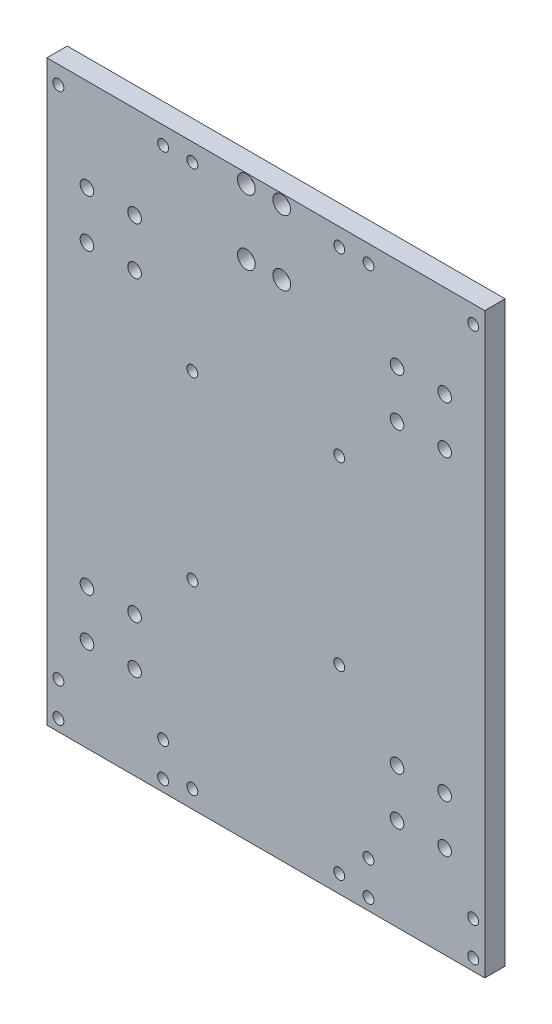
from build123d import *

# Parameters (mm, degrees)
SZKIC1_W                       = 322
SZKIC1_H                       = 425
DODANIE_WYCI_GNI_CIE1_DEPTH    = 15
SZKIC2_R                       = 3
WYTNIJ_WYCI_GNI_CIE1_DEPTH     = 15
SZKIC3_R                       = 5
WYTNIJ_WYCI_GNI_CIE2_DEPTH     = 7
SZYK_LINIOWY1_COUNT            = 2
SZYK_LINIOWY1_PITCH            = 35
SZYK_LINIOWY1_COUNT_DIR2       = 2
SZYK_LINIOWY1_PITCH_DIR2       = 35
SZYK_LINIOWY2_COUNT            = 2
SZYK_LINIOWY2_PITCH            = 228
SZYK_LINIOWY2_COUNT_DIR2       = 2
SZYK_LINIOWY2_PITCH_DIR2       = 254
SZYK_LINIOWY2_COPY_1_SKETCH_R  = 3
SZYK_LINIOWY2_COPY_1_DEPTH     = 15
SZYK_LINIOWY2_COPY_2_SKETCH_R  = 3
SZYK_LINIOWY2_COPY_2_DEPTH     = 15
SZYK_LINIOWY2_COPY_3_SKETCH_R  = 3
SZYK_LINIOWY2_COPY_3_DEPTH     = 15
SZYK_LINIOWY2_COPY_4_SKETCH_R  = 3
SZYK_LINIOWY2_COPY_4_DEPTH     = 15
SZYK_LINIOWY2_COPY_5_SKETCH_R  = 3
SZYK_LINIOWY2_COPY_5_DEPTH     = 15
SZYK_LINIOWY2_COPY_6_SKETCH_R  = 3
SZYK_LINIOWY2_COPY_6_DEPTH     = 15
SZYK_LINIOWY2_COPY_7_SKETCH_R  = 3
SZYK_LINIOWY2_COPY_7_DEPTH     = 15
SZYK_LINIOWY2_COPY_8_SKETCH_R  = 3
SZYK_LINIOWY2_COPY_8_DEPTH     = 15
SZYK_LINIOWY2_COPY_9_SKETCH_R  = 3
SZYK_LINIOWY2_COPY_9_DEPTH     = 15
SZYK_LINIOWY2_COPY_10_SKETCH_R = 5
SZYK_LINIOWY2_COPY_10_DEPTH    = 7
SZYK_LINIOWY2_COPY_11_SKETCH_R = 5
SZYK_LINIOWY2_COPY_11_DEPTH    = 7
SZYK_LINIOWY2_COPY_12_SKETCH_R = 5
SZYK_LINIOWY2_COPY_12_DEPTH    = 7
SZYK_LINIOWY2_COPY_13_SKETCH_R = 5
SZYK_LINIOWY2_COPY_13_DEPTH    = 7
SZYK_LINIOWY2_COPY_14_SKETCH_R = 5
SZYK_LINIOWY2_COPY_14_DEPTH    = 7
SZYK_LINIOWY2_COPY_15_SKETCH_R = 5
SZYK_LINIOWY2_COPY_15_DEPTH    = 7
SZYK_LINIOWY2_COPY_16_SKETCH_R = 5
SZYK_LINIOWY2_COPY_16_DEPTH    = 7
SZYK_LINIOWY2_COPY_17_SKETCH_R = 5
SZYK_LINIOWY2_COPY_17_DEPTH    = 7
SZYK_LINIOWY2_COPY_18_SKETCH_R = 5
SZYK_LINIOWY2_COPY_18_DEPTH    = 7
SZKIC6_R                       = 4
WYTNIJ_WYCI_GNI_CIE3_DEPTH     = 20
SZKIC7_R                       = 4
WYTNIJ_WYCI_GNI_CIE4_DEPTH     = 20
SZKIC10_R                      = 4
WYTNIJ_WYCI_GNI_CIE5_DEPTH     = 21
SZKIC11_R                      = 4
WYTNIJ_WYCI_GNI_CIE6_DEPTH     = 21
SZKIC12_R                      = 3.999999999
WYTNIJ_WYCI_GNI_CIE7_DEPTH     = 15
SZKIC13_R                      = 6.499999999
WYTNIJ_WYCI_GNI_CIE8_DEPTH     = 9
SZKIC14_R                      = 4
WYTNIJ_WYCI_GNI_CIE9_DEPTH     = 15
SZYK_LINIOWY3_COUNT            = 4
SZYK_LINIOWY3_PITCH            = 133


with BuildPart() as part:
    # Szkic1 → Dodanie-wyciągnięcie1 (new body)
    with BuildSketch(Plane.XY):
        Rectangle(SZKIC1_W, SZKIC1_H)
    extrude(amount=DODANIE_WYCI_GNI_CIE1_DEPTH)

    # Szkic2 → Wytnij-wyciągnięcie1 (cut)
    with BuildSketch(Plane.XY.offset(15)):
        with Locations((-131.5, 144.5)):
            Circle(SZKIC2_R)
    wytnij_wyci_gni_cie1 = extrude(amount=-WYTNIJ_WYCI_GNI_CIE1_DEPTH, mode=Mode.SUBTRACT)

    # Szkic3 → Wytnij-wyciągnięcie2 (cut)
    with BuildSketch(Plane.XY.offset(15)):
        with Locations((-131.5, 144.5)):
            Circle(SZKIC3_R)
    wytnij_wyci_gni_cie2 = extrude(amount=-WYTNIJ_WYCI_GNI_CIE2_DEPTH, mode=Mode.SUBTRACT)

    # Szyk liniowy1: Wytnij-wyciągnięcie1, Wytnij-wyci_gni_cie2 2 × 2
    with Locations(*[(i * SZYK_LINIOWY1_PITCH, -j * SZYK_LINIOWY1_PITCH_DIR2, 0) for i in range(SZYK_LINIOWY1_COUNT) for j in range(SZYK_LINIOWY1_COUNT_DIR2) if (i, j) != (0, 0)]):
        add(wytnij_wyci_gni_cie1, mode=Mode.SUBTRACT)
        add(wytnij_wyci_gni_cie2, mode=Mode.SUBTRACT)

    # Szyk liniowy2: Wytnij-wyciągnięcie1, Wytnij-wyci_gni_cie2 2 × 2
    with Locations(*[(i * SZYK_LINIOWY2_PITCH, -j * SZYK_LINIOWY2_PITCH_DIR2, 0) for i in range(SZYK_LINIOWY2_COUNT) for j in range(SZYK_LINIOWY2_COUNT_DIR2) if (i, j) != (0, 0)]):
        add(wytnij_wyci_gni_cie1, mode=Mode.SUBTRACT)
        add(wytnij_wyci_gni_cie2, mode=Mode.SUBTRACT)

    # Szyk liniowy2 copy 1 sketch → Szyk liniowy2 copy 1 (cut)
    with BuildSketch(Plane(origin=(0, -289, 15), x_dir=(1, 0, 0), z_dir=(0, 0, 1))):
        with Locations((-131.5, 144.5)):
            Circle(SZYK_LINIOWY2_COPY_1_SKETCH_R)
    extrude(amount=-SZYK_LINIOWY2_COPY_1_DEPTH, mode=Mode.SUBTRACT)

    # Szyk liniowy2 copy 2 sketch → Szyk liniowy2 copy 2 (cut)
    with BuildSketch(Plane(origin=(228, -35, 15), x_dir=(1, 0, 0), z_dir=(0, 0, 1))):
        with Locations((-131.5, 144.5)):
            Circle(SZYK_LINIOWY2_COPY_2_SKETCH_R)
    extrude(amount=-SZYK_LINIOWY2_COPY_2_DEPTH, mode=Mode.SUBTRACT)

    # Szyk liniowy2 copy 3 sketch → Szyk liniowy2 copy 3 (cut)
    with BuildSketch(Plane(origin=(228, -289, 15), x_dir=(1, 0, 0), z_dir=(0, 0, 1))):
        with Locations((-131.5, 144.5)):
            Circle(SZYK_LINIOWY2_COPY_3_SKETCH_R)
    extrude(amount=-SZYK_LINIOWY2_COPY_3_DEPTH, mode=Mode.SUBTRACT)

    # Szyk liniowy2 copy 4 sketch → Szyk liniowy2 copy 4 (cut)
    with BuildSketch(Plane(origin=(35, -254, 15), x_dir=(1, 0, 0), z_dir=(0, 0, 1))):
        with Locations((-131.5, 144.5)):
            Circle(SZYK_LINIOWY2_COPY_4_SKETCH_R)
    extrude(amount=-SZYK_LINIOWY2_COPY_4_DEPTH, mode=Mode.SUBTRACT)

    # Szyk liniowy2 copy 5 sketch → Szyk liniowy2 copy 5 (cut)
    with BuildSketch(Plane(origin=(263, 0, 15), x_dir=(1, 0, 0), z_dir=(0, 0, 1))):
        with Locations((-131.5, 144.5)):
            Circle(SZYK_LINIOWY2_COPY_5_SKETCH_R)
    extrude(amount=-SZYK_LINIOWY2_COPY_5_DEPTH, mode=Mode.SUBTRACT)

    # Szyk liniowy2 copy 6 sketch → Szyk liniowy2 copy 6 (cut)
    with BuildSketch(Plane(origin=(263, -254, 15), x_dir=(1, 0, 0), z_dir=(0, 0, 1))):
        with Locations((-131.5, 144.5)):
            Circle(SZYK_LINIOWY2_COPY_6_SKETCH_R)
    extrude(amount=-SZYK_LINIOWY2_COPY_6_DEPTH, mode=Mode.SUBTRACT)

    # Szyk liniowy2 copy 7 sketch → Szyk liniowy2 copy 7 (cut)
    with BuildSketch(Plane(origin=(35, -289, 15), x_dir=(1, 0, 0), z_dir=(0, 0, 1))):
        with Locations((-131.5, 144.5)):
            Circle(SZYK_LINIOWY2_COPY_7_SKETCH_R)
    extrude(amount=-SZYK_LINIOWY2_COPY_7_DEPTH, mode=Mode.SUBTRACT)

    # Szyk liniowy2 copy 8 sketch → Szyk liniowy2 copy 8 (cut)
    with BuildSketch(Plane(origin=(263, -35, 15), x_dir=(1, 0, 0), z_dir=(0, 0, 1))):
        with Locations((-131.5, 144.5)):
            Circle(SZYK_LINIOWY2_COPY_8_SKETCH_R)
    extrude(amount=-SZYK_LINIOWY2_COPY_8_DEPTH, mode=Mode.SUBTRACT)

    # Szyk liniowy2 copy 9 sketch → Szyk liniowy2 copy 9 (cut)
    with BuildSketch(Plane(origin=(263, -289, 15), x_dir=(1, 0, 0), z_dir=(0, 0, 1))):
        with Locations((-131.5, 144.5)):
            Circle(SZYK_LINIOWY2_COPY_9_SKETCH_R)
    extrude(amount=-SZYK_LINIOWY2_COPY_9_DEPTH, mode=Mode.SUBTRACT)

    # Szyk liniowy2 copy 10 sketch → Szyk liniowy2 copy 10 (cut)
    with BuildSketch(Plane(origin=(0, -289, 15), x_dir=(1, 0, 0), z_dir=(0, 0, 1))):
        with Locations((-131.5, 144.5)):
            Circle(SZYK_LINIOWY2_COPY_10_SKETCH_R)
    extrude(amount=-SZYK_LINIOWY2_COPY_10_DEPTH, mode=Mode.SUBTRACT)

    # Szyk liniowy2 copy 11 sketch → Szyk liniowy2 copy 11 (cut)
    with BuildSketch(Plane(origin=(228, -35, 15), x_dir=(1, 0, 0), z_dir=(0, 0, 1))):
        with Locations((-131.5, 144.5)):
            Circle(SZYK_LINIOWY2_COPY_11_SKETCH_R)
    extrude(amount=-SZYK_LINIOWY2_COPY_11_DEPTH, mode=Mode.SUBTRACT)

    # Szyk liniowy2 copy 12 sketch → Szyk liniowy2 copy 12 (cut)
    with BuildSketch(Plane(origin=(228, -289, 15), x_dir=(1, 0, 0), z_dir=(0, 0, 1))):
        with Locations((-131.5, 144.5)):
            Circle(SZYK_LINIOWY2_COPY_12_SKETCH_R)
    extrude(amount=-SZYK_LINIOWY2_COPY_12_DEPTH, mode=Mode.SUBTRACT)

    # Szyk liniowy2 copy 13 sketch → Szyk liniowy2 copy 13 (cut)
    with BuildSketch(Plane(origin=(35, -254, 15), x_dir=(1, 0, 0), z_dir=(0, 0, 1))):
        with Locations((-131.5, 144.5)):
            Circle(SZYK_LINIOWY2_COPY_13_SKETCH_R)
    extrude(amount=-SZYK_LINIOWY2_COPY_13_DEPTH, mode=Mode.SUBTRACT)

    # Szyk liniowy2 copy 14 sketch → Szyk liniowy2 copy 14 (cut)
    with BuildSketch(Plane(origin=(263, 0, 15), x_dir=(1, 0, 0), z_dir=(0, 0, 1))):
        with Locations((-131.5, 144.5)):
            Circle(SZYK_LINIOWY2_COPY_14_SKETCH_R)
    extrude(amount=-SZYK_LINIOWY2_COPY_14_DEPTH, mode=Mode.SUBTRACT)

    # Szyk liniowy2 copy 15 sketch → Szyk liniowy2 copy 15 (cut)
    with BuildSketch(Plane(origin=(263, -254, 15), x_dir=(1, 0, 0), z_dir=(0, 0, 1))):
        with Locations((-131.5, 144.5)):
            Circle(SZYK_LINIOWY2_COPY_15_SKETCH_R)
    extrude(amount=-SZYK_LINIOWY2_COPY_15_DEPTH, mode=Mode.SUBTRACT)

    # Szyk liniowy2 copy 16 sketch → Szyk liniowy2 copy 16 (cut)
    with BuildSketch(Plane(origin=(35, -289, 15), x_dir=(1, 0, 0), z_dir=(0, 0, 1))):
        with Locations((-131.5, 144.5)):
            Circle(SZYK_LINIOWY2_COPY_16_SKETCH_R)
    extrude(amount=-SZYK_LINIOWY2_COPY_16_DEPTH, mode=Mode.SUBTRACT)

    # Szyk liniowy2 copy 17 sketch → Szyk liniowy2 copy 17 (cut)
    with BuildSketch(Plane(origin=(263, -35, 15), x_dir=(1, 0, 0), z_dir=(0, 0, 1))):
        with Locations((-131.5, 144.5)):
            Circle(SZYK_LINIOWY2_COPY_17_SKETCH_R)
    extrude(amount=-SZYK_LINIOWY2_COPY_17_DEPTH, mode=Mode.SUBTRACT)

    # Szyk liniowy2 copy 18 sketch → Szyk liniowy2 copy 18 (cut)
    with BuildSketch(Plane(origin=(263, -289, 15), x_dir=(1, 0, 0), z_dir=(0, 0, 1))):
        with Locations((-131.5, 144.5)):
            Circle(SZYK_LINIOWY2_COPY_18_SKETCH_R)
    extrude(amount=-SZYK_LINIOWY2_COPY_18_DEPTH, mode=Mode.SUBTRACT)

    # Szkic6 → Wytnij-wyciągnięcie3 (cut)
    with BuildSketch(Plane.XY.offset(15)):
        with Locations((-152.5, 199.5)):
            Circle(SZKIC6_R)
        with Locations((-75.5, 199.5)):
            Circle(SZKIC6_R)
    extrude(amount=-WYTNIJ_WYCI_GNI_CIE3_DEPTH, mode=Mode.SUBTRACT)

    # Szkic7 → Wytnij-wyciągnięcie4 (cut)
    with BuildSketch(Plane.XY.offset(15)):
        with Locations((-152.5, -204)):
            Circle(SZKIC7_R)
        with Locations((-152.5, -179)):
            Circle(SZKIC7_R)
        with Locations((-75.5, -204)):
            Circle(SZKIC7_R)
        with Locations((-75.5, -179)):
            Circle(SZKIC7_R)
    extrude(amount=-WYTNIJ_WYCI_GNI_CIE4_DEPTH, mode=Mode.SUBTRACT)

    # Szkic10 → Wytnij-wyciągnięcie5 (cut)
    with BuildSketch(Plane.XY.offset(15)):
        with Locations((75.5, 199.5)):
            Circle(SZKIC10_R)
        with Locations((152.5, 199.5)):
            Circle(SZKIC10_R)
    extrude(amount=-WYTNIJ_WYCI_GNI_CIE5_DEPTH, mode=Mode.SUBTRACT)

    # Szkic11 → Wytnij-wyciągnięcie6 (cut)
    with BuildSketch(Plane.XY.offset(15)):
        with Locations((152.5, -179)):
            Circle(SZKIC11_R)
        with Locations((152.5, -204)):
            Circle(SZKIC11_R)
        with Locations((75.5, -204)):
            Circle(SZKIC11_R)
        with Locations((75.5, -179)):
            Circle(SZKIC11_R)
    extrude(amount=-WYTNIJ_WYCI_GNI_CIE6_DEPTH, mode=Mode.SUBTRACT)

    # Szkic12 → Wytnij-wyciągnięcie7 (cut)
    with BuildSketch(Plane.XY.offset(15)):
        with Locations((-14.3, 205.5)):
            Circle(SZKIC12_R)
        with Locations((11.7, 205.5)):
            Circle(SZKIC12_R)
        with Locations((-14.3, 157.5)):
            Circle(SZKIC12_R)
        with Locations((11.7, 157.5)):
            Circle(SZKIC12_R)
    extrude(amount=-WYTNIJ_WYCI_GNI_CIE7_DEPTH, mode=Mode.SUBTRACT)

    # Szkic13 → Wytnij-wyciągnięcie8 (cut)
    with BuildSketch(Plane.XY.offset(15)):
        with Locations((-14.3, 205.5)):
            Circle(SZKIC13_R)
        with Locations((11.7, 205.5)):
            Circle(SZKIC13_R)
        with Locations((11.7, 157.5)):
            Circle(SZKIC13_R)
        with Locations((-14.3, 157.5)):
            Circle(SZKIC13_R)
    extrude(amount=-WYTNIJ_WYCI_GNI_CIE8_DEPTH, mode=Mode.SUBTRACT)

    # Szkic14 → Wytnij-wyciągnięcie9 (cut)
    with BuildSketch(Plane.XY.offset(15)):
        with Locations((-54, 199.5)):
            Circle(SZKIC14_R)
        with Locations((54, 199.5)):
            Circle(SZKIC14_R)
    wytnij_wyci_gni_cie9 = extrude(amount=-WYTNIJ_WYCI_GNI_CIE9_DEPTH, mode=Mode.SUBTRACT)

    # Szyk liniowy3: Wytnij-wyciągnięcie9 ×4
    with Locations(*[(0, -i * SZYK_LINIOWY3_PITCH, 0) for i in range(1, SZYK_LINIOWY3_COUNT)]):
        add(wytnij_wyci_gni_cie9, mode=Mode.SUBTRACT)


solid = part.part
